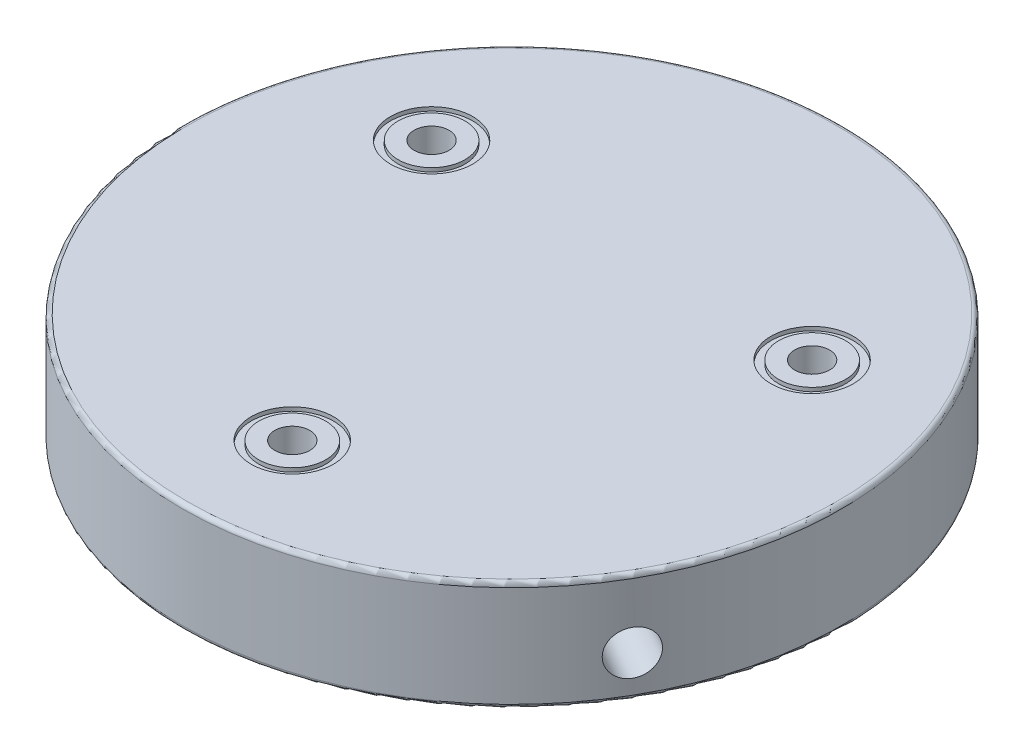
from build123d import *

# Parameters (mm, degrees)
SKETCH1_R           = 38.1
BOSS_EXTRUDE1_DEPTH = 12.7
SKETCH2_R           = 15.875
CUT_EXTRUDE1_DEPTH  = 9.525
SKETCH3_R           = 2.0193
CUT_EXTRUDE2_DEPTH  = 12.7
CIRPATTERN1_COUNT   = 3
CUT_EXTRUDE3_START  = -38.1
SKETCH4_R           = 2.5527
CUT_EXTRUDE3_DEPTH  = 22.431581
CIRPATTERN2_COUNT   = 3
FILLET1_R           = 0.508
SKETCH5_R           = 4.7625
SKETCH5_R_2         = 3.8735
CUT_EXTRUDE4_DEPTH  = 0.4445
CIRPATTERN3_COUNT   = 3


with BuildPart() as part:
    # Sketch1 → Boss-Extrude1 (new body)
    with BuildSketch(Plane(origin=(0, 0, 0), x_dir=(1, 0, 0), z_dir=(0, 1, 0))):
        Circle(SKETCH1_R)
    extrude(amount=BOSS_EXTRUDE1_DEPTH)

    # Sketch2 → Cut-Extrude1 (cut)
    with BuildSketch(Plane.XZ):
        Circle(SKETCH2_R)
    extrude(amount=-CUT_EXTRUDE1_DEPTH, mode=Mode.SUBTRACT)

    # Sketch3 → Cut-Extrude2 (cut)
    with BuildSketch(Plane.XZ):
        with Locations((0, 25.4)):
            Circle(SKETCH3_R)
    cut_extrude2 = extrude(amount=-CUT_EXTRUDE2_DEPTH, mode=Mode.SUBTRACT)

    # CirPattern1: Cut-Extrude2 ×3 about axis
    cirpattern1_axis = Axis((0, 0, 0), (0, 1, 0))
    for i in range(1, CIRPATTERN1_COUNT):
        add(cut_extrude2.rotate(cirpattern1_axis, i * 360 / CIRPATTERN1_COUNT), mode=Mode.SUBTRACT)

    # Sketch4 → Cut-Extrude3 (cut)
    with BuildSketch(Plane.XY.offset(CUT_EXTRUDE3_START)):
        with Locations((0, 4.7625)):
            Circle(SKETCH4_R)
    cut_extrude3 = extrude(amount=CUT_EXTRUDE3_DEPTH, mode=Mode.SUBTRACT)

    # CirPattern2: Cut-Extrude3 ×3 about axis
    cirpattern2_axis = Axis((0, 0, 0), (0, 1, 0))
    for i in range(1, CIRPATTERN2_COUNT):
        add(cut_extrude3.rotate(cirpattern2_axis, i * 360 / CIRPATTERN2_COUNT), mode=Mode.SUBTRACT)

    # Fillet1
    fillet1_edges = [part.edges().sort_by_distance(p)[0] for p in [
        (-38.1, 0, 0),
        (-38.1, 12.7, 0),
        (-15.875, 0, 0),
    ]]
    fillet(fillet1_edges, radius=FILLET1_R)

    # Sketch5 → Cut-Extrude4 (cut)
    with BuildSketch(Plane(origin=(0, 12.7, 0), x_dir=(1, 0, 0), z_dir=(0, 1, 0))):
        with Locations((0, -25.4)):
            Circle(SKETCH5_R)
        with Locations((0, -25.4)):
            Circle(SKETCH5_R_2, mode=Mode.SUBTRACT)
    cut_extrude4 = extrude(amount=-CUT_EXTRUDE4_DEPTH, mode=Mode.SUBTRACT)

    # CirPattern3: Cut-Extrude4 ×3 about axis
    cirpattern3_axis = Axis((0, 0, 0), (0, 1, 0))
    for i in range(1, CIRPATTERN3_COUNT):
        add(cut_extrude4.rotate(cirpattern3_axis, i * 360 / CIRPATTERN3_COUNT), mode=Mode.SUBTRACT)


solid = part.part
